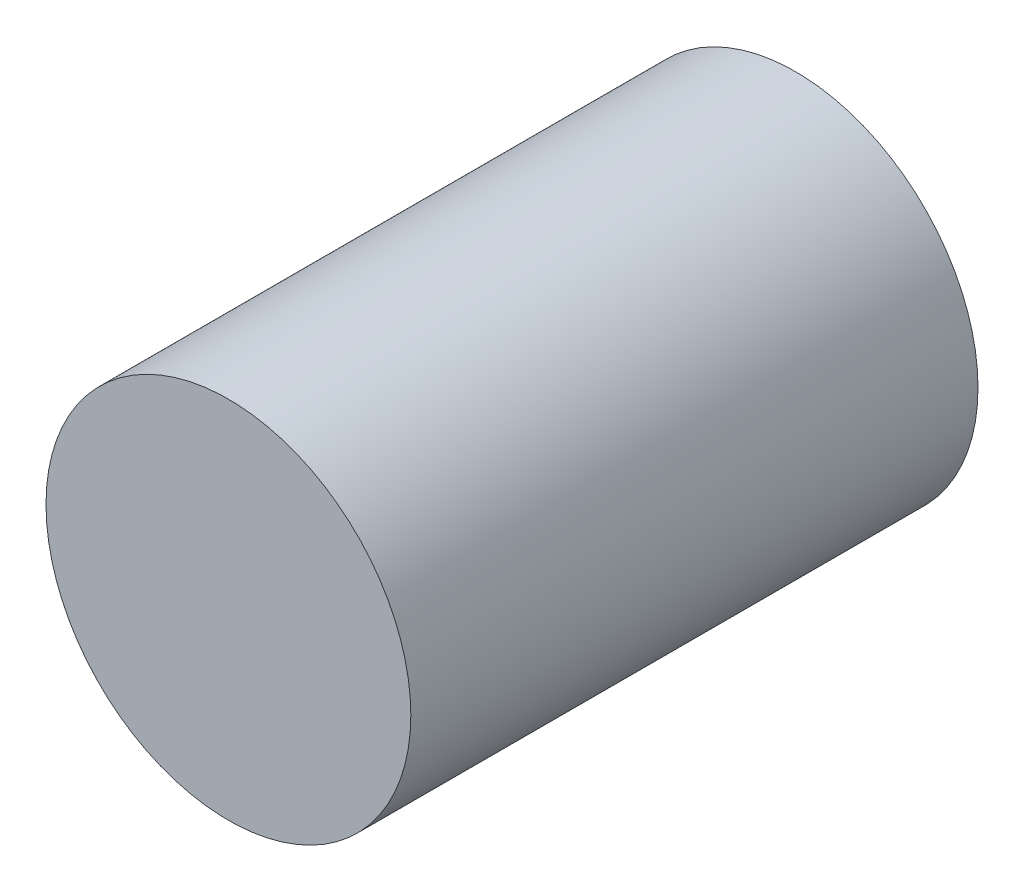
from build123d import *

# Parameters (mm, degrees)
SKETCH1_R           = 1.5875
BOSS_EXTRUDE1_DEPTH = 7.62
SKETCH2_R           = 18.3
BOSS_EXTRUDE2_DEPTH = 56.9


with BuildPart() as part:
    # Sketch1 → Boss-Extrude1 (new body)
    with BuildSketch(Plane.XY):
        Circle(SKETCH1_R)
    extrude(amount=BOSS_EXTRUDE1_DEPTH)

    # Sketch2 → Boss-Extrude2 (add)
    with BuildSketch(Plane.XY.offset(7.62)):
        Circle(SKETCH2_R)
    extrude(amount=BOSS_EXTRUDE2_DEPTH)


solid = part.part
